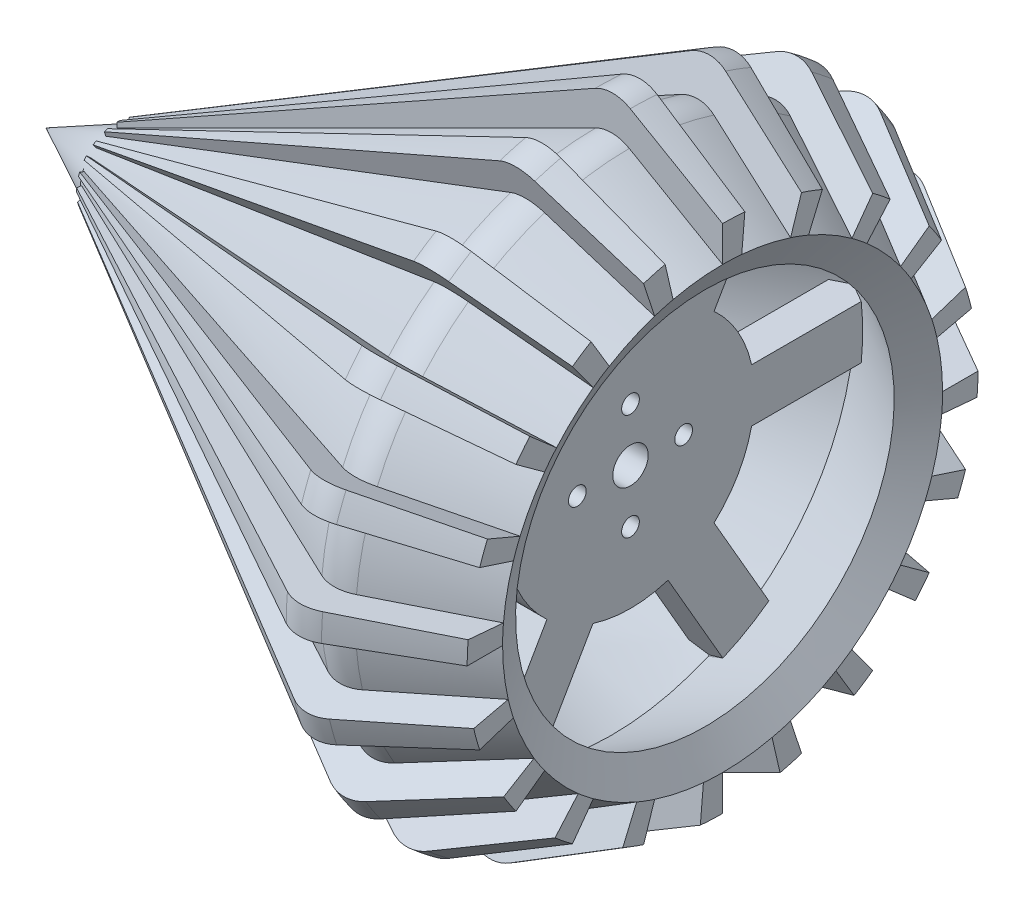
from build123d import *

# Parameters (mm, degrees)
REVOLVE8_ANGLE      = 5
CIRPATTERN3_COUNT   = 20
FILLET2_R           = 12.7
SKETCH4_R           = 6.35
SKETCH4_R_2         = 3.175
BOSS_EXTRUDE1_DEPTH = 6.35
SKETCH5_R           = 6.35
BOSS_EXTRUDE2_DEPTH = 6.35


with BuildPart() as part:
    # Sketch2 → Revolve1 (revolve)
    with BuildSketch(Plane.XY):
        Polygon((39.369890216, 78.869783286), (0, 101.6), (-203.2, 0), (-174.801936686, 0), (-0.432231925, 87.184852381), (33.019890216, 67.871260658), align=None)
    revolve(axis=Axis((33.461450024, 0, 0), (-1, 0, 0)))


with BuildPart() as body_2:
    # Sketch3 → Revolve8 (revolve)
    with BuildSketch(Plane.XY):
        Polygon((-177.8, 14.461868907), (0, 114.3), (39.369890216, 91.569783286), (39.369890216, 78.869783286), (0, 101.6), (-177.8, 12.7), align=None)
    revolve(axis=Axis((95.945299933, 0, 0), (-1, 0, 0)), revolution_arc=REVOLVE8_ANGLE)


with BuildPart() as cirpattern3_1:
    # CirPattern3: pattern copy
    add(body_2.part.rotate(Axis((0, 0, 0), (1, 0, 0)), 1 * 360 / CIRPATTERN3_COUNT))


with BuildPart() as cirpattern3_2:
    # CirPattern3: pattern copy
    add(body_2.part.rotate(Axis((0, 0, 0), (1, 0, 0)), 2 * 360 / CIRPATTERN3_COUNT))


with BuildPart() as cirpattern3_3:
    # CirPattern3: pattern copy
    add(body_2.part.rotate(Axis((0, 0, 0), (1, 0, 0)), 3 * 360 / CIRPATTERN3_COUNT))


with BuildPart() as cirpattern3_4:
    # CirPattern3: pattern copy
    add(body_2.part.rotate(Axis((0, 0, 0), (1, 0, 0)), 4 * 360 / CIRPATTERN3_COUNT))


with BuildPart() as cirpattern3_5:
    # CirPattern3: pattern copy
    add(body_2.part.rotate(Axis((0, 0, 0), (1, 0, 0)), 5 * 360 / CIRPATTERN3_COUNT))


with BuildPart() as cirpattern3_6:
    # CirPattern3: pattern copy
    add(body_2.part.rotate(Axis((0, 0, 0), (1, 0, 0)), 6 * 360 / CIRPATTERN3_COUNT))


with BuildPart() as cirpattern3_7:
    # CirPattern3: pattern copy
    add(body_2.part.rotate(Axis((0, 0, 0), (1, 0, 0)), 7 * 360 / CIRPATTERN3_COUNT))


with BuildPart() as cirpattern3_8:
    # CirPattern3: pattern copy
    add(body_2.part.rotate(Axis((0, 0, 0), (1, 0, 0)), 8 * 360 / CIRPATTERN3_COUNT))


with BuildPart() as cirpattern3_9:
    # CirPattern3: pattern copy
    add(body_2.part.rotate(Axis((0, 0, 0), (1, 0, 0)), 9 * 360 / CIRPATTERN3_COUNT))


with BuildPart() as cirpattern3_10:
    # CirPattern3: pattern copy
    add(body_2.part.rotate(Axis((0, 0, 0), (1, 0, 0)), 10 * 360 / CIRPATTERN3_COUNT))


with BuildPart() as cirpattern3_11:
    # CirPattern3: pattern copy
    add(body_2.part.rotate(Axis((0, 0, 0), (1, 0, 0)), 11 * 360 / CIRPATTERN3_COUNT))


with BuildPart() as cirpattern3_12:
    # CirPattern3: pattern copy
    add(body_2.part.rotate(Axis((0, 0, 0), (1, 0, 0)), 12 * 360 / CIRPATTERN3_COUNT))


with BuildPart() as cirpattern3_13:
    # CirPattern3: pattern copy
    add(body_2.part.rotate(Axis((0, 0, 0), (1, 0, 0)), 13 * 360 / CIRPATTERN3_COUNT))


with BuildPart() as cirpattern3_14:
    # CirPattern3: pattern copy
    add(body_2.part.rotate(Axis((0, 0, 0), (1, 0, 0)), 14 * 360 / CIRPATTERN3_COUNT))


with BuildPart() as cirpattern3_15:
    # CirPattern3: pattern copy
    add(body_2.part.rotate(Axis((0, 0, 0), (1, 0, 0)), 15 * 360 / CIRPATTERN3_COUNT))


with BuildPart() as cirpattern3_16:
    # CirPattern3: pattern copy
    add(body_2.part.rotate(Axis((0, 0, 0), (1, 0, 0)), 16 * 360 / CIRPATTERN3_COUNT))


with BuildPart() as cirpattern3_17:
    # CirPattern3: pattern copy
    add(body_2.part.rotate(Axis((0, 0, 0), (1, 0, 0)), 17 * 360 / CIRPATTERN3_COUNT))


with BuildPart() as cirpattern3_18:
    # CirPattern3: pattern copy
    add(body_2.part.rotate(Axis((0, 0, 0), (1, 0, 0)), 18 * 360 / CIRPATTERN3_COUNT))


with BuildPart() as cirpattern3_19:
    # CirPattern3: pattern copy
    add(body_2.part.rotate(Axis((0, 0, 0), (1, 0, 0)), 19 * 360 / CIRPATTERN3_COUNT))

    # Combine1: union body 2, CirPattern3_1, CirPattern3_2, CirPattern3_3, part, CirPattern3_4, CirPattern3_5, CirPattern3_6, CirPattern3_7, CirPattern3_8, CirPattern3_9, CirPattern3_10, CirPattern3_11, CirPattern3_12, CirPattern3_13, CirPattern3_15, CirPattern3_14, CirPattern3_16, CirPattern3_17, CirPattern3_18
    add(body_2.part)
    add(cirpattern3_1.part)
    add(cirpattern3_2.part)
    add(cirpattern3_3.part)
    add(part.part)
    add(cirpattern3_4.part)
    add(cirpattern3_5.part)
    add(cirpattern3_6.part)
    add(cirpattern3_7.part)
    add(cirpattern3_8.part)
    add(cirpattern3_9.part)
    add(cirpattern3_10.part)
    add(cirpattern3_11.part)
    add(cirpattern3_12.part)
    add(cirpattern3_13.part)
    add(cirpattern3_15.part)
    add(cirpattern3_14.part)
    add(cirpattern3_16.part)
    add(cirpattern3_17.part)
    add(cirpattern3_18.part)

    # Fillet2
    fillet2_edges = [cirpattern3_19.edges().sort_by_distance(p)[0] for p in [
        (0, 99.560349989, -20.255782137),
        (0, 114.191211727, -4.985695976),
        (0, 100.946900537, 11.501446519),
        (0, 110.142960802, 30.545346386),
        (0, 92.452065121, 42.132833454),
        (0, 95.313149462, 63.086397421),
        (0, 74.90737742, 68.639965094),
        (0, 71.153422968, 89.452112328),
        (0, 50.030233707, 88.428138707),
        (0, 88.428138707, -50.030233707),
        (0, 68.639965094, -74.90737742),
        (0, 42.132833454, -92.452065121),
        (0, -20.255782137, -99.560349989),
        (0, 11.501446519, -100.946900537),
        (0, -50.030233707, -88.428138707),
        (0, -74.90737742, -68.639965094),
        (0, -92.452065121, -42.132833454),
        (0, -100.946900537, -11.501446519),
        (0, -99.560349989, 20.255782137),
        (0, -88.428138707, 50.030233707),
        (0, -68.639965094, 74.90737742),
        (0, -42.132833454, 92.452065121),
        (0, -11.501446519, 100.946900537),
        (0, 20.255782137, 99.560349989),
        (0, 40.028703678, 107.061631231),
        (0, 4.985695976, 114.191211727),
        (0, -30.545346386, 110.142960802),
        (0, -63.086397421, 95.313149462),
        (0, -89.452112328, 71.153422968),
        (0, -107.061631231, 40.028703678),
        (0, -114.191211727, 4.985695976),
        (0, -110.142960802, -30.545346386),
        (0, -95.313149462, -63.086397421),
        (0, -71.153422968, -89.452112328),
        (0, -4.985695976, -114.191211727),
        (0, -40.028703678, -107.061631231),
        (0, 30.545346386, -110.142960802),
        (0, 63.086397421, -95.313149462),
        (0, 89.452112328, -71.153422968),
        (0, 107.061631231, -40.028703678),
    ]]
    fillet(fillet2_edges, radius=FILLET2_R)

    # Sketch4 → Boss-Extrude1 (add, symmetric)
    with BuildSketch(Plane(origin=(0, 0, 0), x_dir=(0, 0, -1), z_dir=(1, 0, 0))):
        with BuildLine():
            Line((29.957627972, -32.838133721), (55.873891971, -77.72641971))
            Line((55.873891971, -77.72641971), (39.376108029, -87.25141971))
            Line((39.376108029, -87.25141971), (13.45984403, -42.363133721))
            ThreePointArc((13.45984403, -42.363133721), (0, -44.45), (-13.45984403, -42.363133721))
            Line((-13.45984403, -42.363133721), (-39.376108029, -87.25141971))
            Line((-39.376108029, -87.25141971), (-55.873891971, -77.72641971))
            Line((-55.873891971, -77.72641971), (-29.957627972, -32.838133721))
            ThreePointArc((-29.957627972, -32.838133721), (-38.494829198, -22.225), (-43.417472001, -9.525))
            Line((-43.417472001, -9.525), (-95.25, -9.525))
            Line((-95.25, -9.525), (-95.25, 9.525))
            Line((-95.25, 9.525), (-43.417472001, 9.525))
            ThreePointArc((-43.417472001, 9.525), (-38.494829198, 22.225), (-29.957627972, 32.838133721))
            Line((-29.957627972, 32.838133721), (-55.873891971, 77.72641971))
            Line((-55.873891971, 77.72641971), (-39.376108029, 87.25141971))
            Line((-39.376108029, 87.25141971), (-13.45984403, 42.363133721))
            ThreePointArc((-13.45984403, 42.363133721), (0, 44.45), (13.45984403, 42.363133721))
            Line((13.45984403, 42.363133721), (39.376108029, 87.25141971))
            Line((39.376108029, 87.25141971), (55.873891971, 77.72641971))
            Line((55.873891971, 77.72641971), (29.957627972, 32.838133721))
            ThreePointArc((29.957627972, 32.838133721), (38.494829198, 22.225), (43.417472001, 9.525))
            Line((43.417472001, 9.525), (95.25, 9.525))
            Line((95.25, 9.525), (95.25, -9.525))
            Line((95.25, -9.525), (43.417472001, -9.525))
            ThreePointArc((43.417472001, -9.525), (38.494829198, -22.225), (29.957627972, -32.838133721))
        make_face()
        Circle(SKETCH4_R, mode=Mode.SUBTRACT)
        with Locations((0, 19.05)):
            Circle(SKETCH4_R_2, mode=Mode.SUBTRACT)
        with Locations((19.05, 0)):
            Circle(SKETCH4_R_2, mode=Mode.SUBTRACT)
        with Locations((0, -19.05)):
            Circle(SKETCH4_R_2, mode=Mode.SUBTRACT)
        with Locations((-19.05, 0)):
            Circle(SKETCH4_R_2, mode=Mode.SUBTRACT)
    extrude(amount=BOSS_EXTRUDE1_DEPTH, both=True)


with BuildPart() as body_2_2:
    # Sketch5 → Boss-Extrude2 (new, symmetric)
    with BuildSketch(Plane(origin=(-127, 0, 0), x_dir=(0, 0, -1), z_dir=(1, 0, 0))):
        with BuildLine():
            Line((24.593444248, 6.35), (44.45, 6.35))
            Line((44.45, 6.35), (44.45, -6.35))
            Line((44.45, -6.35), (24.593444248, -6.35))
            ThreePointArc((24.593444248, -6.35), (21.997045256, -12.7), (17.795983438, -18.123547486))
            Line((17.795983438, -18.123547486), (27.724261314, -35.319829198))
            Line((27.724261314, -35.319829198), (16.725738686, -41.669829198))
            Line((16.725738686, -41.669829198), (6.79746081, -24.473547486))
            ThreePointArc((6.79746081, -24.473547486), (0, -25.4), (-6.79746081, -24.473547486))
            Line((-6.79746081, -24.473547486), (-16.725738686, -41.669829198))
            Line((-16.725738686, -41.669829198), (-27.724261314, -35.319829198))
            Line((-27.724261314, -35.319829198), (-17.795983438, -18.123547486))
            ThreePointArc((-17.795983438, -18.123547486), (-21.997045256, -12.7), (-24.593444248, -6.35))
            Line((-24.593444248, -6.35), (-44.45, -6.35))
            Line((-44.45, -6.35), (-44.45, 6.35))
            Line((-44.45, 6.35), (-24.593444248, 6.35))
            ThreePointArc((-24.593444248, 6.35), (-21.997045256, 12.7), (-17.795983438, 18.123547486))
            Line((-17.795983438, 18.123547486), (-27.724261314, 35.319829198))
            Line((-27.724261314, 35.319829198), (-16.725738686, 41.669829198))
            Line((-16.725738686, 41.669829198), (-6.79746081, 24.473547486))
            ThreePointArc((-6.79746081, 24.473547486), (0, 25.4), (6.79746081, 24.473547486))
            Line((6.79746081, 24.473547486), (16.725738686, 41.669829198))
            Line((16.725738686, 41.669829198), (27.724261314, 35.319829198))
            Line((27.724261314, 35.319829198), (17.795983438, 18.123547486))
            ThreePointArc((17.795983438, 18.123547486), (21.997045256, 12.7), (24.593444248, 6.35))
        make_face()
        Circle(SKETCH5_R, mode=Mode.SUBTRACT)
    extrude(amount=BOSS_EXTRUDE2_DEPTH, both=True)

    # Sketch6 → Cut-Revolve2 (revolve, cut)
    with BuildSketch(Plane.XY, mode=Mode.PRIVATE) as cut_revolve2_sk:
        Polygon((-180.028062503, 11.585968749), (-92.052710638, 53.66778179), (-98.551098176, 67.253173883), (-180.028062503, 28.279776138), align=None)
    revolve(cut_revolve2_sk.sketch.rotate(Axis((-279.640332464, 0, 0), (1, 0, 0)), 203.431665371), axis=Axis((-279.640332464, 0, 0), (1, 0, 0)), mode=Mode.SUBTRACT)


solid = Compound([cirpattern3_19.part, body_2_2.part])
